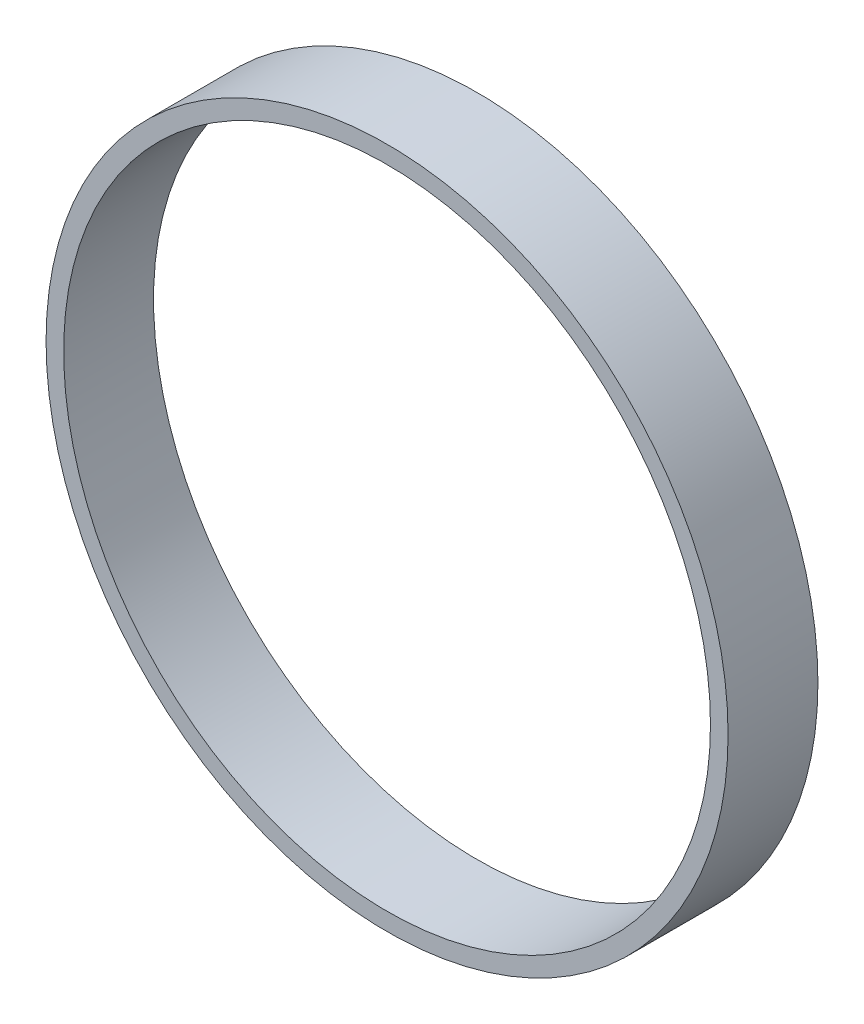
from build123d import *

# Parameters (mm, degrees)
SKETCH1_R           = 37.95
SKETCH1_R_2         = 35.99
BOSS_EXTRUDE1_DEPTH = 10


with BuildPart() as part:
    # Sketch1 → Boss-Extrude1 (new body)
    with BuildSketch(Plane.XY):
        Circle(SKETCH1_R)
        Circle(SKETCH1_R_2, mode=Mode.SUBTRACT)
    extrude(amount=BOSS_EXTRUDE1_DEPTH)


solid = part.part
